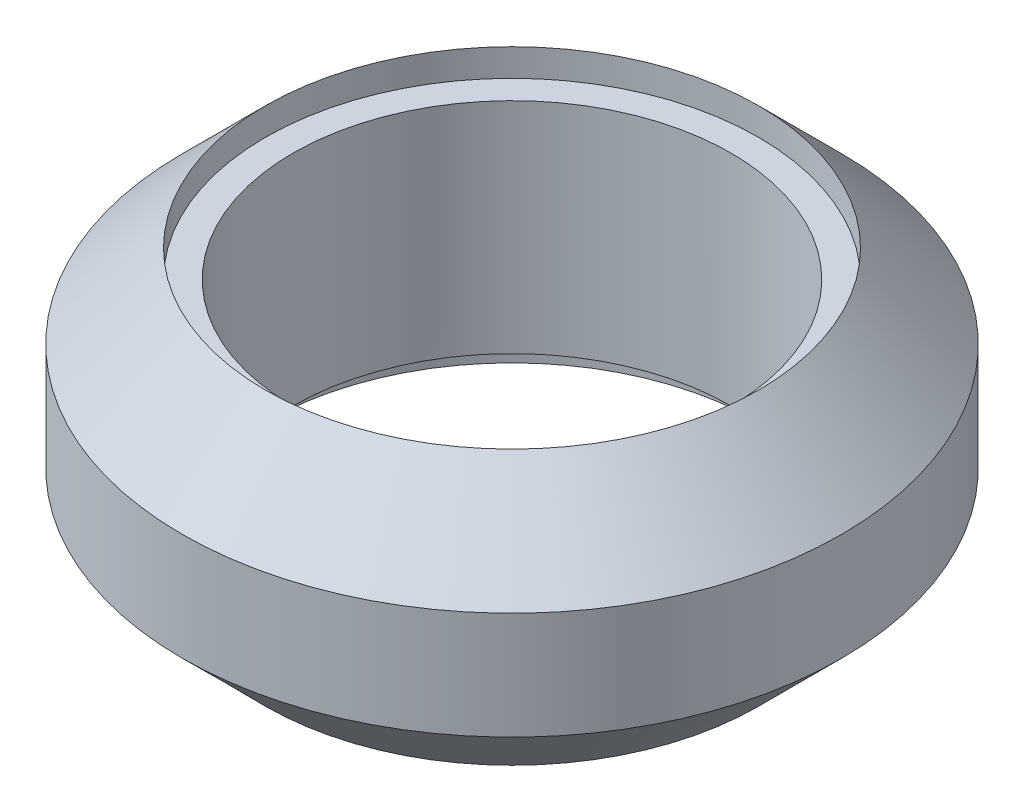
from build123d import *

# Parameters (mm, degrees)
SKETCH1_R           = 9
BOSS_EXTRUDE3_DEPTH = 10
SKETCH54_R          = 12.040559159
BOSS_EXTRUDE5_DEPTH = 3.040559
BOSS_EXTRUDE5_TAPER = 45
SKETCH55_R          = 12.040559159
BOSS_EXTRUDE6_DEPTH = 3.040559
BOSS_EXTRUDE6_TAPER = 45
SKETCH56_R          = 12.040559159
BOSS_EXTRUDE7_DEPTH = 3.918882
SKETCH53_R          = 8
CUT_EXTRUDE7_DEPTH  = 11.0000001
SKETCH57_R          = 9
SKETCH57_R_2        = 8
CUT_EXTRUDE8_DEPTH  = 1
SKETCH59_R          = 9
SKETCH59_R_2        = 8
CUT_EXTRUDE9_DEPTH  = 1


with BuildPart() as part:
    # Sketch1 → Boss-Extrude3 (new body)
    with BuildSketch(Plane(origin=(0, 0, 0), x_dir=(1, 0, 0), z_dir=(0, 1, 0))):
        Circle(SKETCH1_R)
    extrude(amount=BOSS_EXTRUDE3_DEPTH)

    # Sketch54 → Boss-Extrude5 (add)
    with BuildSketch(Plane(origin=(0, 6.959440841, 0), x_dir=(1, 0, 0), z_dir=(0, 1, 0))):
        Circle(SKETCH54_R)
    extrude(amount=BOSS_EXTRUDE5_DEPTH, taper=BOSS_EXTRUDE5_TAPER)

    # Sketch55 → Boss-Extrude6 (add)
    with BuildSketch(Plane.XZ.offset(-3.040559159)):
        Circle(SKETCH55_R)
    extrude(amount=BOSS_EXTRUDE6_DEPTH, taper=BOSS_EXTRUDE6_TAPER)

    # Sketch56 → Boss-Extrude7 (add)
    with BuildSketch(Plane(origin=(0, 6.959440841, 0), x_dir=(-1, 0, 0), z_dir=(0, -1, 0))):
        Circle(SKETCH56_R)
    extrude(amount=BOSS_EXTRUDE7_DEPTH)

    # Sketch53 → Cut-Extrude7 (cut, through all)
    with BuildSketch(Plane(origin=(0, 10, 0), x_dir=(1, 0, 0), z_dir=(0, 1, 0))):
        Circle(SKETCH53_R)
    extrude(amount=-CUT_EXTRUDE7_DEPTH, mode=Mode.SUBTRACT)

    # Sketch57 → Cut-Extrude8 (cut)
    with BuildSketch(Plane(origin=(0, 0, 0), x_dir=(-1, 0, 0), z_dir=(0, -1, 0))):
        Circle(SKETCH57_R)
        Circle(SKETCH57_R_2, mode=Mode.SUBTRACT)
    extrude(amount=-CUT_EXTRUDE8_DEPTH, mode=Mode.SUBTRACT)

    # Sketch59 → Cut-Extrude9 (cut)
    with BuildSketch(Plane(origin=(0, 10, 0), x_dir=(1, 0, 0), z_dir=(0, 1, 0))):
        Circle(SKETCH59_R)
        Circle(SKETCH59_R_2, mode=Mode.SUBTRACT)
    extrude(amount=-CUT_EXTRUDE9_DEPTH, mode=Mode.SUBTRACT)


solid = part.part
